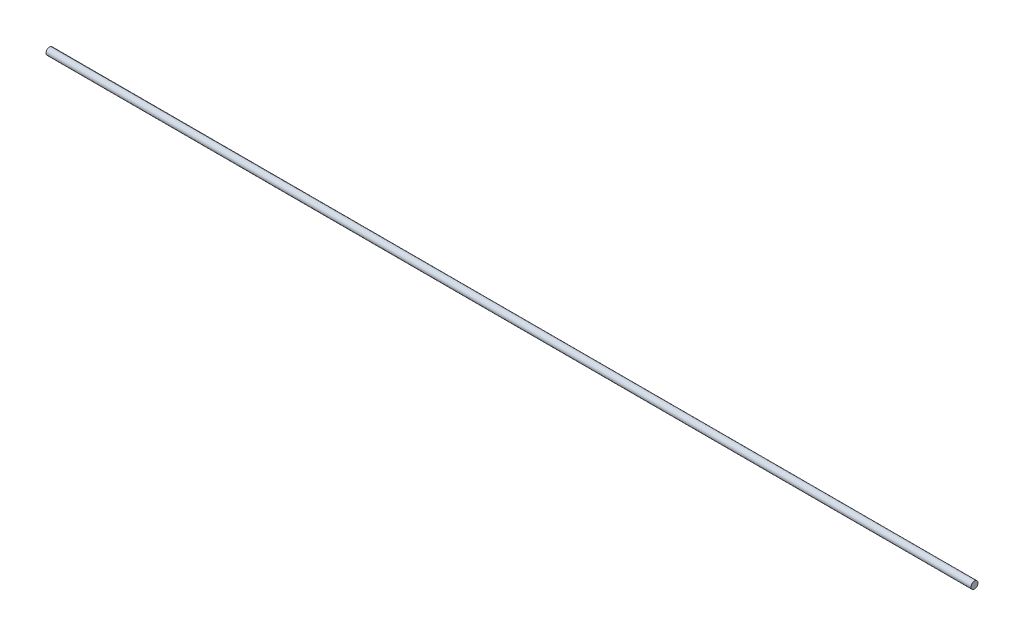
from build123d import *

# Parameters (mm, degrees)
SKETCH1_R           = 3.175
BOSS_EXTRUDE1_DEPTH = 838.2


with BuildPart() as part:
    # Sketch1 → Boss-Extrude1 (new body)
    with BuildSketch(Plane(origin=(0, 0, 0), x_dir=(0, 0, -1), z_dir=(1, 0, 0))):
        Circle(SKETCH1_R)
    extrude(amount=BOSS_EXTRUDE1_DEPTH)


solid = part.part
